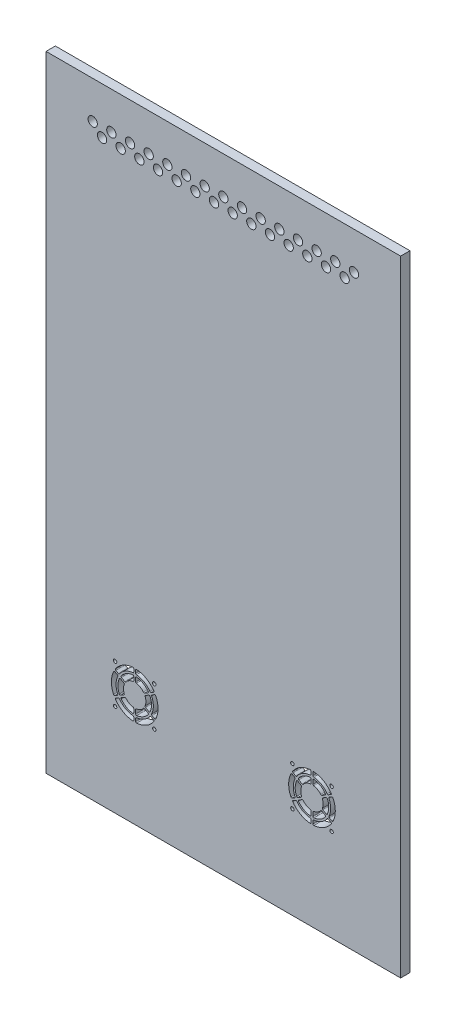
from build123d import *

# Parameters (mm, degrees)
ESQUISSE1_W             = 380
ESQUISSE1_H             = 670
BOSS_EXTRU_1_DEPTH      = 10
ESQUISSE2_R             = 1.85
ENL_V_MAT_EXTRU_1_DEPTH = 11
ESQUISSE3_R             = 5
ENL_V_MAT_EXTRU_2_DEPTH = 11


with BuildPart() as part:
    # Esquisse1 → Boss.-Extru.1 (new body)
    with BuildSketch(Plane.XY):
        Rectangle(ESQUISSE1_W, ESQUISSE1_H)
    extrude(amount=BOSS_EXTRU_1_DEPTH)

    # Esquisse2 → Enlèv. mat.-Extru.1 (cut, through all)
    with BuildSketch(Plane(origin=(0, 0, 0), x_dir=(-1, 0, 0), z_dir=(0, 0, -1))):
        with Locations((-116, -194)):
            Circle(ESQUISSE2_R)
        with Locations((-74, -194)):
            Circle(ESQUISSE2_R)
        with Locations((-74, -236)):
            Circle(ESQUISSE2_R)
        with Locations((-116, -236)):
            Circle(ESQUISSE2_R)
        with Locations(Location((116, -236, 0), (0, 0, 180))):  # turned: the seam where the file's is
            Circle(ESQUISSE2_R)
        with Locations(Location((74, -236, 0), (0, 0, 180))):  # turned: the seam where the file's is
            Circle(ESQUISSE2_R)
        with Locations(Location((74, -194, 0), (0, 0, 180))):  # turned: the seam where the file's is
            Circle(ESQUISSE2_R)
        with Locations(Location((116, -194, 0), (0, 0, 180))):  # turned: the seam where the file's is
            Circle(ESQUISSE2_R)
        with BuildLine():
            Line((-76.39613301, -205.413752924), (-73.787684823, -203.907764661))
            ThreePointArc((-73.787684823, -203.907764661), (-72.988808984, -203.819498058), (-72.383005024, -204.347697984))
            ThreePointArc((-72.383005024, -204.347697984), (-70, -215), (-72.383005024, -225.652302016))
            ThreePointArc((-72.383005024, -225.652302016), (-72.988808984, -226.180501942), (-73.787684823, -226.092235339))
            Line((-73.787684823, -226.092235339), (-76.39613301, -224.586247076))
            ThreePointArc((-76.39613301, -224.586247076), (-76.848621817, -224.024795263), (-76.805840962, -223.304973022))
            ThreePointArc((-76.805840962, -223.304973022), (-75, -215), (-76.805840962, -206.695026978))
            ThreePointArc((-76.805840962, -206.695026978), (-76.848621817, -205.975204737), (-76.39613301, -205.413752924))
        make_face()
        with BuildLine():
            Line((-94, -202.154767421), (-94, -198.118056984))
            ThreePointArc((-94, -198.118056984), (-93.664211164, -197.370511982), (-92.882352941, -197.125001512))
            ThreePointArc((-92.882352941, -197.125001512), (-86, -199.411542732), (-80.578620746, -204.228564607))
            ThreePointArc((-80.578620746, -204.228564607), (-80.400309939, -205.028428925), (-80.879808483, -205.693003088))
            Line((-80.879808483, -205.693003088), (-84.375702269, -207.711358307))
            ThreePointArc((-84.375702269, -207.711358307), (-85.059225719, -207.828348235), (-85.654494402, -207.472614987))
            ThreePointArc((-85.654494402, -207.472614987), (-89, -204.607695155), (-93.153846154, -203.142862235))
            ThreePointArc((-93.153846154, -203.142862235), (-93.759554525, -202.805211057), (-94, -202.154767421))
        make_face()
        with BuildLine():
            Line((-96, -202.154767421), (-96, -198.118056984))
            ThreePointArc((-96, -198.118056984), (-96.335788836, -197.370511982), (-97.117647059, -197.125001512))
            ThreePointArc((-97.117647059, -197.125001512), (-104, -199.411542732), (-109.421379254, -204.228564607))
            ThreePointArc((-109.421379254, -204.228564607), (-109.599690061, -205.028428925), (-109.120191517, -205.693003088))
            Line((-109.120191517, -205.693003088), (-105.624297731, -207.711358307))
            ThreePointArc((-105.624297731, -207.711358307), (-104.940774281, -207.828348235), (-104.345505598, -207.472614987))
            ThreePointArc((-104.345505598, -207.472614987), (-101, -204.607695155), (-96.846153846, -203.142862235))
            ThreePointArc((-96.846153846, -203.142862235), (-96.240445475, -202.805211057), (-96, -202.154767421))
        make_face()
        with BuildLine():
            Line((-83.375702269, -209.443409114), (-79.879808483, -207.425053896))
            ThreePointArc((-79.879808483, -207.425053896), (-79.064521103, -207.342083057), (-78.460973688, -207.896436905))
            ThreePointArc((-78.460973688, -207.896436905), (-77, -215), (-78.460973688, -222.103563095))
            ThreePointArc((-78.460973688, -222.103563095), (-79.064521103, -222.657916943), (-79.879808483, -222.574946104))
            Line((-79.879808483, -222.574946104), (-83.375702269, -220.556590886))
            ThreePointArc((-83.375702269, -220.556590886), (-83.818780244, -220.023137178), (-83.808340556, -219.329752752))
            ThreePointArc((-83.808340556, -219.329752752), (-83, -215), (-83.808340556, -210.670247248))
            ThreePointArc((-83.808340556, -210.670247248), (-83.818780244, -209.976862822), (-83.375702269, -209.443409114))
        make_face()
        with BuildLine():
            Line((-84.375702269, -222.288641693), (-80.879808483, -224.306996912))
            ThreePointArc((-80.879808483, -224.306996912), (-80.400309939, -224.971571075), (-80.578620746, -225.771435393))
            ThreePointArc((-80.578620746, -225.771435393), (-86, -230.588457268), (-92.882352941, -232.874998488))
            ThreePointArc((-92.882352941, -232.874998488), (-93.664211164, -232.629488018), (-94, -231.881943016))
            Line((-94, -231.881943016), (-94, -227.845232579))
            ThreePointArc((-94, -227.845232579), (-93.759554525, -227.194788943), (-93.153846154, -226.857137765))
            ThreePointArc((-93.153846154, -226.857137765), (-89, -225.392304845), (-85.654494402, -222.527385013))
            ThreePointArc((-85.654494402, -222.527385013), (-85.059225719, -222.171651765), (-84.375702269, -222.288641693))
        make_face()
        with BuildLine():
            Line((-96, -227.845232579), (-96, -231.881943016))
            ThreePointArc((-96, -231.881943016), (-96.335788836, -232.629488018), (-97.117647059, -232.874998488))
            ThreePointArc((-97.117647059, -232.874998488), (-104, -230.588457268), (-109.421379254, -225.771435393))
            ThreePointArc((-109.421379254, -225.771435393), (-109.599690061, -224.971571075), (-109.120191517, -224.306996912))
            Line((-109.120191517, -224.306996912), (-105.624297731, -222.288641693))
            ThreePointArc((-105.624297731, -222.288641693), (-104.940774281, -222.171651765), (-104.345505598, -222.527385013))
            ThreePointArc((-104.345505598, -222.527385013), (-101, -225.392304845), (-96.846153846, -226.857137765))
            ThreePointArc((-96.846153846, -226.857137765), (-96.240445475, -227.194788943), (-96, -227.845232579))
        make_face()
        with BuildLine():
            Line((-106.624297731, -220.556590886), (-110.120191517, -222.574946104))
            ThreePointArc((-110.120191517, -222.574946104), (-110.935478897, -222.657916943), (-111.539026312, -222.103563095))
            ThreePointArc((-111.539026312, -222.103563095), (-113, -215), (-111.539026312, -207.896436905))
            ThreePointArc((-111.539026312, -207.896436905), (-110.935478897, -207.342083057), (-110.120191517, -207.425053896))
            Line((-110.120191517, -207.425053896), (-106.624297731, -209.443409114))
            ThreePointArc((-106.624297731, -209.443409114), (-106.181219756, -209.976862822), (-106.191659444, -210.670247248))
            ThreePointArc((-106.191659444, -210.670247248), (-107, -215), (-106.191659444, -219.329752752))
            ThreePointArc((-106.191659444, -219.329752752), (-106.181219756, -220.023137178), (-106.624297731, -220.556590886))
        make_face()
        with BuildLine():
            Line((-113.60386699, -224.586247076), (-116.212315177, -226.092235339))
            ThreePointArc((-116.212315177, -226.092235339), (-117.011191016, -226.180501942), (-117.616994976, -225.652302016))
            ThreePointArc((-117.616994976, -225.652302016), (-120, -215), (-117.616994976, -204.347697984))
            ThreePointArc((-117.616994976, -204.347697984), (-117.011191016, -203.819498058), (-116.212315177, -203.907764661))
            Line((-116.212315177, -203.907764661), (-113.60386699, -205.413752924))
            ThreePointArc((-113.60386699, -205.413752924), (-113.151378183, -205.975204737), (-113.194159038, -206.695026978))
            ThreePointArc((-113.194159038, -206.695026978), (-115, -215), (-113.194159038, -223.304973022))
            ThreePointArc((-113.194159038, -223.304973022), (-113.151378183, -224.024795263), (-113.60386699, -224.586247076))
        make_face()
        with BuildLine():
            Line((-112.60386699, -226.318297884), (-115.212315177, -227.824286147))
            ThreePointArc((-115.212315177, -227.824286147), (-115.688194217, -228.471999617), (-115.533661643, -229.260741199))
            ThreePointArc((-115.533661643, -229.260741199), (-107.5, -236.650635095), (-97.083333333, -239.913043215))
            ThreePointArc((-97.083333333, -239.913043215), (-96.3229968, -239.652501558), (-96, -238.916521486))
            Line((-96, -238.916521486), (-96, -235.90454496))
            ThreePointArc((-96, -235.90454496), (-96.25998713, -235.231952251), (-96.904761905, -234.909090438))
            ThreePointArc((-96.904761905, -234.909090438), (-105, -232.320508076), (-111.289397134, -226.604117417))
            ThreePointArc((-111.289397134, -226.604117417), (-111.891391053, -226.207156989), (-112.60386699, -226.318297884))
        make_face()
        with BuildLine():
            Line((-94, -235.90454496), (-94, -238.916521486))
            ThreePointArc((-94, -238.916521486), (-93.6770032, -239.652501558), (-92.916666667, -239.913043215))
            ThreePointArc((-92.916666667, -239.913043215), (-82.5, -236.650635095), (-74.466338357, -229.260741199))
            ThreePointArc((-74.466338357, -229.260741199), (-74.311805783, -228.471999617), (-74.787684823, -227.824286147))
            Line((-74.787684823, -227.824286147), (-77.39613301, -226.318297884))
            ThreePointArc((-77.39613301, -226.318297884), (-78.108608947, -226.207156989), (-78.710602866, -226.604117417))
            ThreePointArc((-78.710602866, -226.604117417), (-85, -232.320508076), (-93.095238095, -234.909090438))
            ThreePointArc((-93.095238095, -234.909090438), (-93.74001287, -235.231952251), (-94, -235.90454496))
        make_face()
        with BuildLine():
            Line((-77.39613301, -203.681702116), (-74.787684823, -202.175713853))
            ThreePointArc((-74.787684823, -202.175713853), (-74.311805783, -201.528000383), (-74.466338357, -200.739258801))
            ThreePointArc((-74.466338357, -200.739258801), (-82.5, -193.349364905), (-92.916666667, -190.086956785))
            ThreePointArc((-92.916666667, -190.086956785), (-93.6770032, -190.347498442), (-94, -191.083478514))
            Line((-94, -191.083478514), (-94, -194.09545504))
            ThreePointArc((-94, -194.09545504), (-93.74001287, -194.768047749), (-93.095238095, -195.090909562))
            ThreePointArc((-93.095238095, -195.090909562), (-85, -197.679491924), (-78.710602866, -203.395882583))
            ThreePointArc((-78.710602866, -203.395882583), (-78.108608947, -203.792843011), (-77.39613301, -203.681702116))
        make_face()
        with BuildLine():
            Line((-96, -194.09545504), (-96, -191.083478514))
            ThreePointArc((-96, -191.083478514), (-96.3229968, -190.347498442), (-97.083333333, -190.086956785))
            ThreePointArc((-97.083333333, -190.086956785), (-107.5, -193.349364905), (-115.533661643, -200.739258801))
            ThreePointArc((-115.533661643, -200.739258801), (-115.688194217, -201.528000383), (-115.212315177, -202.175713853))
            Line((-115.212315177, -202.175713853), (-112.60386699, -203.681702116))
            ThreePointArc((-112.60386699, -203.681702116), (-111.891391053, -203.792843011), (-111.289397134, -203.395882583))
            ThreePointArc((-111.289397134, -203.395882583), (-105, -197.679491924), (-96.904761905, -195.090909562))
            ThreePointArc((-96.904761905, -195.090909562), (-96.25998713, -194.768047749), (-96, -194.09545504))
        make_face()
        with BuildLine():
            Line((113.60386699, -205.413752924), (116.212315177, -203.907764661))
            ThreePointArc((116.212315177, -203.907764661), (117.011191016, -203.819498058), (117.616994976, -204.347697984))
            ThreePointArc((117.616994976, -204.347697984), (120, -215), (117.616994976, -225.652302016))
            ThreePointArc((117.616994976, -225.652302016), (117.011191016, -226.180501942), (116.212315177, -226.092235339))
            Line((116.212315177, -226.092235339), (113.60386699, -224.586247076))
            ThreePointArc((113.60386699, -224.586247076), (113.151378183, -224.024795263), (113.194159038, -223.304973022))
            ThreePointArc((113.194159038, -223.304973022), (115, -215), (113.194159038, -206.695026978))
            ThreePointArc((113.194159038, -206.695026978), (113.151378183, -205.975204737), (113.60386699, -205.413752924))
        make_face()
        with BuildLine():
            Line((112.60386699, -203.681702116), (115.212315177, -202.175713853))
            ThreePointArc((115.212315177, -202.175713853), (115.688194217, -201.528000383), (115.533661643, -200.739258801))
            ThreePointArc((115.533661643, -200.739258801), (107.5, -193.349364905), (97.083333333, -190.086956785))
            ThreePointArc((97.083333333, -190.086956785), (96.3229968, -190.347498442), (96, -191.083478514))
            Line((96, -191.083478514), (96, -194.09545504))
            ThreePointArc((96, -194.09545504), (96.25998713, -194.768047749), (96.904761905, -195.090909562))
            ThreePointArc((96.904761905, -195.090909562), (105, -197.679491924), (111.289397134, -203.395882583))
            ThreePointArc((111.289397134, -203.395882583), (111.891391053, -203.792843011), (112.60386699, -203.681702116))
        make_face()
        with BuildLine():
            Line((94, -194.09545504), (94, -191.083478514))
            ThreePointArc((94, -191.083478514), (93.6770032, -190.347498442), (92.916666667, -190.086956785))
            ThreePointArc((92.916666667, -190.086956785), (82.5, -193.349364905), (74.466338357, -200.739258801))
            ThreePointArc((74.466338357, -200.739258801), (74.311805783, -201.528000383), (74.787684823, -202.175713853))
            Line((74.787684823, -202.175713853), (77.39613301, -203.681702116))
            ThreePointArc((77.39613301, -203.681702116), (78.108608947, -203.792843011), (78.710602866, -203.395882583))
            ThreePointArc((78.710602866, -203.395882583), (85, -197.679491924), (93.095238095, -195.090909562))
            ThreePointArc((93.095238095, -195.090909562), (93.74001287, -194.768047749), (94, -194.09545504))
        make_face()
        with BuildLine():
            Line((76.39613301, -205.413752924), (73.787684823, -203.907764661))
            ThreePointArc((73.787684823, -203.907764661), (72.988808984, -203.819498058), (72.383005024, -204.347697984))
            ThreePointArc((72.383005024, -204.347697984), (70, -215), (72.383005024, -225.652302016))
            ThreePointArc((72.383005024, -225.652302016), (72.988808984, -226.180501942), (73.787684823, -226.092235339))
            Line((73.787684823, -226.092235339), (76.39613301, -224.586247076))
            ThreePointArc((76.39613301, -224.586247076), (76.848621817, -224.024795263), (76.805840962, -223.304973022))
            ThreePointArc((76.805840962, -223.304973022), (75, -215), (76.805840962, -206.695026978))
            ThreePointArc((76.805840962, -206.695026978), (76.848621817, -205.975204737), (76.39613301, -205.413752924))
        make_face()
        with BuildLine():
            Line((77.39613301, -226.318297884), (74.787684823, -227.824286147))
            ThreePointArc((74.787684823, -227.824286147), (74.311805783, -228.471999617), (74.466338357, -229.260741199))
            ThreePointArc((74.466338357, -229.260741199), (82.5, -236.650635095), (92.916666667, -239.913043215))
            ThreePointArc((92.916666667, -239.913043215), (93.6770032, -239.652501558), (94, -238.916521486))
            Line((94, -238.916521486), (94, -235.90454496))
            ThreePointArc((94, -235.90454496), (93.74001287, -235.231952251), (93.095238095, -234.909090438))
            ThreePointArc((93.095238095, -234.909090438), (85, -232.320508076), (78.710602866, -226.604117417))
            ThreePointArc((78.710602866, -226.604117417), (78.108608947, -226.207156989), (77.39613301, -226.318297884))
        make_face()
        with BuildLine():
            Line((96, -235.90454496), (96, -238.916521486))
            ThreePointArc((96, -238.916521486), (96.3229968, -239.652501558), (97.083333333, -239.913043215))
            ThreePointArc((97.083333333, -239.913043215), (107.5, -236.650635095), (115.533661643, -229.260741199))
            ThreePointArc((115.533661643, -229.260741199), (115.688194217, -228.471999617), (115.212315177, -227.824286147))
            Line((115.212315177, -227.824286147), (112.60386699, -226.318297884))
            ThreePointArc((112.60386699, -226.318297884), (111.891391053, -226.207156989), (111.289397134, -226.604117417))
            ThreePointArc((111.289397134, -226.604117417), (105, -232.320508076), (96.904761905, -234.909090438))
            ThreePointArc((96.904761905, -234.909090438), (96.25998713, -235.231952251), (96, -235.90454496))
        make_face()
        with BuildLine():
            Line((106.624297731, -209.443409114), (110.120191517, -207.425053896))
            ThreePointArc((110.120191517, -207.425053896), (110.935478897, -207.342083057), (111.539026312, -207.896436905))
            ThreePointArc((111.539026312, -207.896436905), (113, -215), (111.539026312, -222.103563095))
            ThreePointArc((111.539026312, -222.103563095), (110.935478897, -222.657916943), (110.120191517, -222.574946104))
            Line((110.120191517, -222.574946104), (106.624297731, -220.556590886))
            ThreePointArc((106.624297731, -220.556590886), (106.181219756, -220.023137178), (106.191659444, -219.329752752))
            ThreePointArc((106.191659444, -219.329752752), (107, -215), (106.191659444, -210.670247248))
            ThreePointArc((106.191659444, -210.670247248), (106.181219756, -209.976862822), (106.624297731, -209.443409114))
        make_face()
        with BuildLine():
            Line((105.624297731, -207.711358307), (109.120191517, -205.693003088))
            ThreePointArc((109.120191517, -205.693003088), (109.599690061, -205.028428925), (109.421379254, -204.228564607))
            ThreePointArc((109.421379254, -204.228564607), (104, -199.411542732), (97.117647059, -197.125001512))
            ThreePointArc((97.117647059, -197.125001512), (96.335788836, -197.370511982), (96, -198.118056984))
            Line((96, -198.118056984), (96, -202.154767421))
            ThreePointArc((96, -202.154767421), (96.240445475, -202.805211057), (96.846153846, -203.142862235))
            ThreePointArc((96.846153846, -203.142862235), (101, -204.607695155), (104.345505598, -207.472614987))
            ThreePointArc((104.345505598, -207.472614987), (104.940774281, -207.828348235), (105.624297731, -207.711358307))
        make_face()
        with BuildLine():
            Line((105.624297731, -222.288641693), (109.120191517, -224.306996912))
            ThreePointArc((109.120191517, -224.306996912), (109.599690061, -224.971571075), (109.421379254, -225.771435393))
            ThreePointArc((109.421379254, -225.771435393), (104, -230.588457268), (97.117647059, -232.874998488))
            ThreePointArc((97.117647059, -232.874998488), (96.335788836, -232.629488018), (96, -231.881943016))
            Line((96, -231.881943016), (96, -227.845232579))
            ThreePointArc((96, -227.845232579), (96.240445475, -227.194788943), (96.846153846, -226.857137765))
            ThreePointArc((96.846153846, -226.857137765), (101, -225.392304845), (104.345505598, -222.527385013))
            ThreePointArc((104.345505598, -222.527385013), (104.940774281, -222.171651765), (105.624297731, -222.288641693))
        make_face()
        with BuildLine():
            Line((94, -227.845232579), (94, -231.881943016))
            ThreePointArc((94, -231.881943016), (93.664211164, -232.629488018), (92.882352941, -232.874998488))
            ThreePointArc((92.882352941, -232.874998488), (86, -230.588457268), (80.578620746, -225.771435393))
            ThreePointArc((80.578620746, -225.771435393), (80.400309939, -224.971571075), (80.879808483, -224.306996912))
            Line((80.879808483, -224.306996912), (84.375702269, -222.288641693))
            ThreePointArc((84.375702269, -222.288641693), (85.059225719, -222.171651765), (85.654494402, -222.527385013))
            ThreePointArc((85.654494402, -222.527385013), (89, -225.392304845), (93.153846154, -226.857137765))
            ThreePointArc((93.153846154, -226.857137765), (93.759554525, -227.194788943), (94, -227.845232579))
        make_face()
        with BuildLine():
            Line((83.375702269, -220.556590886), (79.879808483, -222.574946104))
            ThreePointArc((79.879808483, -222.574946104), (79.064521103, -222.657916943), (78.460973688, -222.103563095))
            ThreePointArc((78.460973688, -222.103563095), (77, -215), (78.460973688, -207.896436905))
            ThreePointArc((78.460973688, -207.896436905), (79.064521103, -207.342083057), (79.879808483, -207.425053896))
            Line((79.879808483, -207.425053896), (83.375702269, -209.443409114))
            ThreePointArc((83.375702269, -209.443409114), (83.818780244, -209.976862822), (83.808340556, -210.670247248))
            ThreePointArc((83.808340556, -210.670247248), (83, -215), (83.808340556, -219.329752752))
            ThreePointArc((83.808340556, -219.329752752), (83.818780244, -220.023137178), (83.375702269, -220.556590886))
        make_face()
        with BuildLine():
            Line((84.375702269, -207.711358307), (80.879808483, -205.693003088))
            ThreePointArc((80.879808483, -205.693003088), (80.400309939, -205.028428925), (80.578620746, -204.228564607))
            ThreePointArc((80.578620746, -204.228564607), (86, -199.411542732), (92.882352941, -197.125001512))
            ThreePointArc((92.882352941, -197.125001512), (93.664211164, -197.370511982), (94, -198.118056984))
            Line((94, -198.118056984), (94, -202.154767421))
            ThreePointArc((94, -202.154767421), (93.759554525, -202.805211057), (93.153846154, -203.142862235))
            ThreePointArc((93.153846154, -203.142862235), (89, -204.607695155), (85.654494402, -207.472614987))
            ThreePointArc((85.654494402, -207.472614987), (85.059225719, -207.828348235), (84.375702269, -207.711358307))
        make_face()
    extrude(amount=-ENL_V_MAT_EXTRU_1_DEPTH, mode=Mode.SUBTRACT)

    # Esquisse3 → Enlèv. mat.-Extru.2 (cut, through all)
    with BuildSketch(Plane(origin=(0, 0, 0), x_dir=(-1, 0, 0), z_dir=(0, 0, -1))):
        with Locations((-140, 295)):
            Circle(ESQUISSE3_R)
        with Locations((-130, 285)):
            Circle(ESQUISSE3_R)
        with Locations((-120, 295)):
            Circle(ESQUISSE3_R)
        with Locations((-110, 285)):
            Circle(ESQUISSE3_R)
        with Locations((-100, 295)):
            Circle(ESQUISSE3_R)
        with Locations((-90, 285)):
            Circle(ESQUISSE3_R)
        with Locations((-80, 295)):
            Circle(ESQUISSE3_R)
        with Locations((-70, 285)):
            Circle(ESQUISSE3_R)
        with Locations((-60, 295)):
            Circle(ESQUISSE3_R)
        with Locations((-50, 285)):
            Circle(ESQUISSE3_R)
        with Locations((-40, 295)):
            Circle(ESQUISSE3_R)
        with Locations((-30, 285)):
            Circle(ESQUISSE3_R)
        with Locations((-20, 295)):
            Circle(ESQUISSE3_R)
        with Locations((-10, 285)):
            Circle(ESQUISSE3_R)
        with Locations((0, 295)):
            Circle(ESQUISSE3_R)
        with Locations((10, 285)):
            Circle(ESQUISSE3_R)
        with Locations((20, 295)):
            Circle(ESQUISSE3_R)
        with Locations((30, 285)):
            Circle(ESQUISSE3_R)
        with Locations((40, 295)):
            Circle(ESQUISSE3_R)
        with Locations((50, 285)):
            Circle(ESQUISSE3_R)
        with Locations((60, 295)):
            Circle(ESQUISSE3_R)
        with Locations((70, 285)):
            Circle(ESQUISSE3_R)
        with Locations((80, 295)):
            Circle(ESQUISSE3_R)
        with Locations((90, 285)):
            Circle(ESQUISSE3_R)
        with Locations((100, 295)):
            Circle(ESQUISSE3_R)
        with Locations((110, 285)):
            Circle(ESQUISSE3_R)
        with Locations((120, 295)):
            Circle(ESQUISSE3_R)
        with Locations((130, 285)):
            Circle(ESQUISSE3_R)
        with Locations((140, 295)):
            Circle(ESQUISSE3_R)
    extrude(amount=-ENL_V_MAT_EXTRU_2_DEPTH, mode=Mode.SUBTRACT)


solid = part.part
